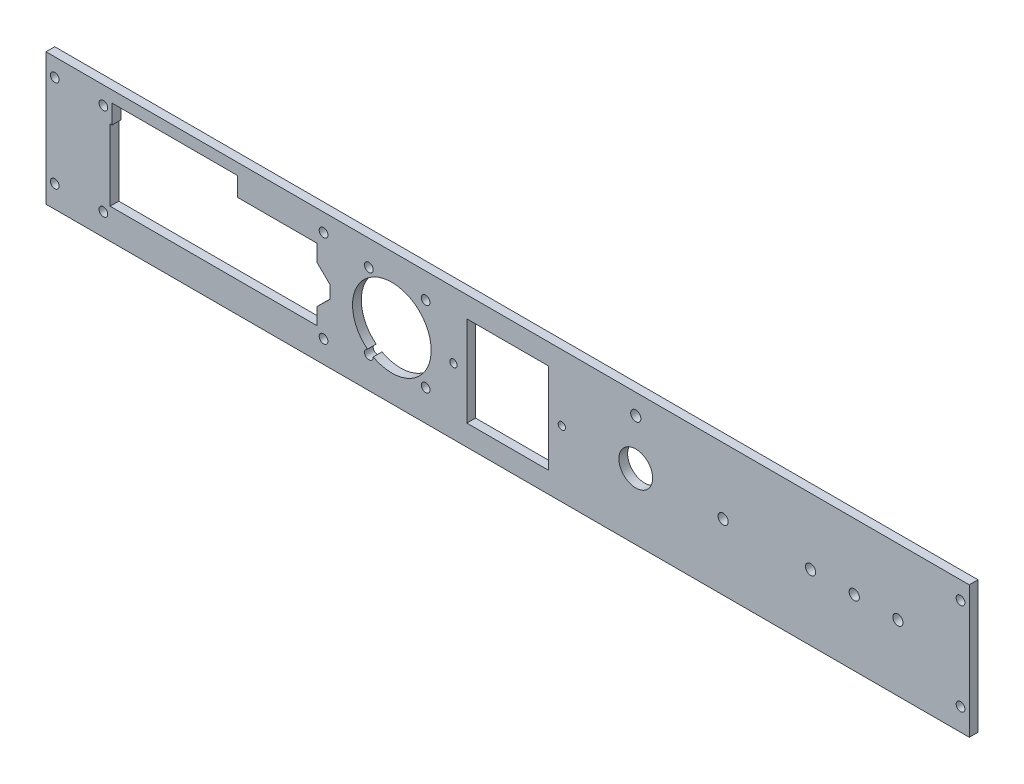
from build123d import *

# Parameters (mm, degrees)
SKETCH1_W               = 323
SKETCH1_H               = 45.34
BOSS_EXTRUDE1_DEPTH     = 3
SKETCH2_W               = 71
SKETCH2_H               = 24.5
SKETCH2_R               = 13.5
SKETCH2_W_2             = 28
SKETCH2_H_2             = 31
SKETCH2_R_2             = 5.8
SKETCH2_R_3             = 1.75
CUT_EXTRUDE1_DEPTH      = 1
CUT_EXTRUDE1_DEPTH_BACK = 4
SKETCH3_R               = 1.5
SKETCH3_W               = 43
SKETCH3_H               = 7
CUT_EXTRUDE2_DEPTH      = 10
CUT_EXTRUDE4_DEPTH      = 10
SKETCH6_W               = 3
SKETCH6_H               = 45.34
CUT_EXTRUDE5_DEPTH      = 10
SKETCH7_R               = 1.5
CUT_EXTRUDE6_DEPTH      = 4


with BuildPart() as part:
    # Sketch1 → Boss-Extrude1 (new body)
    with BuildSketch(Plane.XY):
        Rectangle(SKETCH1_W, SKETCH1_H)
    extrude(amount=BOSS_EXTRUDE1_DEPTH)

    # Sketch2 → Cut-Extrude1 (cut, two sides)
    with BuildSketch(Plane.XY.offset(3)) as cut_extrude1_sk:
        with Locations((-101, 0)):
            Rectangle(SKETCH2_W, SKETCH2_H)
        Polygon((-61, 2.2), (-65.5, 6.6), (-65.5, -6.6), (-61, -2.2), align=None)
        with Locations((-39.75, 0)):
            Circle(SKETCH2_R)
        Rectangle(SKETCH2_W_2, SKETCH2_H_2)
        with Locations((44, 0)):
            Circle(SKETCH2_R_2)
        with Locations((44, 15.67)):
            Circle(SKETCH2_R_3)
        with Locations((74, 0)):
            Circle(SKETCH2_R_3)
        with Locations((104, 0)):
            Circle(SKETCH2_R_3)
        with Locations((119, 0)):
            Circle(SKETCH2_R_3)
        with Locations((134, 0)):
            Circle(SKETCH2_R_3)
    extrude(amount=CUT_EXTRUDE1_DEPTH, mode=Mode.SUBTRACT)
    extrude(cut_extrude1_sk.sketch, amount=-CUT_EXTRUDE1_DEPTH_BACK, mode=Mode.SUBTRACT)

    # Sketch3 → Cut-Extrude2 (cut)
    with BuildSketch(Plane(origin=(0, 0, 0), x_dir=(-1, 0, 0), z_dir=(0, 0, -1))):
        with Locations((63.2, 16.55)):
            Circle(SKETCH3_R)
        with Locations((63.2, -15.05)):
            Circle(SKETCH3_R)
        with Locations((138.8, -15.05)):
            Circle(SKETCH3_R)
        with Locations((138.8, 16.55)):
            Circle(SKETCH3_R)
        with Locations((155.5, 16.55)):
            Circle(SKETCH3_R)
        with Locations((155.5, -15.05)):
            Circle(SKETCH3_R)
        with Locations(Location((-155.5, -15.05, 0), (0, 0, 180))):  # turned: the seam where the file's is
            Circle(SKETCH3_R)
        with Locations(Location((-155.5, 16.55, 0), (0, 0, 180))):  # turned: the seam where the file's is
            Circle(SKETCH3_R)
        with Locations((114.3, 15.25)):
            Rectangle(SKETCH3_W, SKETCH3_H)
    extrude(amount=-CUT_EXTRUDE2_DEPTH, mode=Mode.SUBTRACT)

    # Sketch5 → Cut-Extrude4 (cut)
    with BuildSketch(Plane.XY.offset(3)):
        with BuildLine():
            ThreePointArc((18.6, -1.25), (19.85, 0), (18.6, 1.25))
            ThreePointArc((18.6, 1.25), (17.35, 0), (18.6, -1.25))
        make_face()
        with BuildLine():
            ThreePointArc((-18.6, -1.25), (-17.35, 0), (-18.6, 1.25))
            ThreePointArc((-18.6, 1.25), (-19.85, 0), (-18.6, -1.25))
        make_face()
    extrude(amount=-CUT_EXTRUDE4_DEPTH, mode=Mode.SUBTRACT)

    # Sketch6 → Cut-Extrude5 (cut)
    with BuildSketch(Plane.XY.offset(3)):
        with Locations((-160, 0)):
            Rectangle(SKETCH6_W, SKETCH6_H)
        with Locations((160, 0)):
            Rectangle(SKETCH6_W, SKETCH6_H)
    extrude(amount=-CUT_EXTRUDE5_DEPTH, mode=Mode.SUBTRACT)

    # Sketch7 → Cut-Extrude6 (cut, through all)
    with BuildSketch(Plane(origin=(0, 0, 0), x_dir=(-1, 0, 0), z_dir=(0, 0, -1))):
        with Locations((28.15, -12)):
            Circle(SKETCH7_R)
        with Locations((47.65, -12)):
            Circle(SKETCH7_R)
        with Locations((47.65, 14)):
            Circle(SKETCH7_R)
        with Locations((28.15, 14)):
            Circle(SKETCH7_R)
    extrude(amount=-CUT_EXTRUDE6_DEPTH, mode=Mode.SUBTRACT)


solid = part.part
